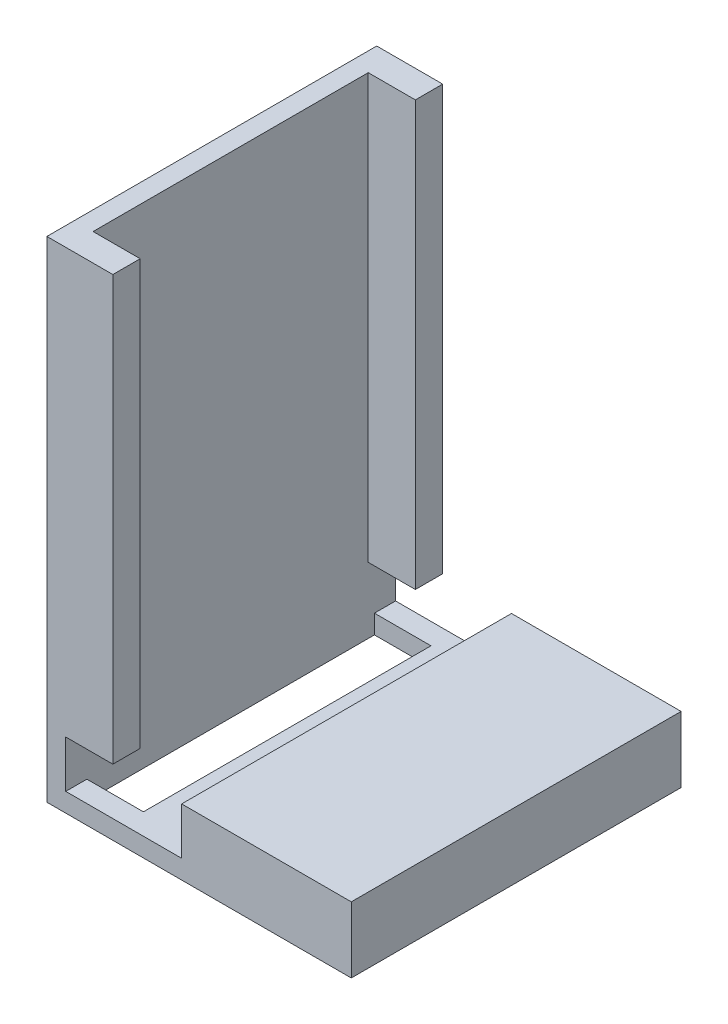
from build123d import *

# Parameters (mm, degrees)
SKETCH1_W           = 18
SKETCH1_H           = 5
SKETCH1_W_2         = 2
SKETCH1_H_2         = 2
SKETCH1_H_3         = 50
BOSS_EXTRUDE1_DEPTH = 35
SKETCH2_W           = 2.9
SKETCH2_H           = 45
BOSS_EXTRUDE2_DEPTH = 5
SKETCH3_W           = 6
SKETCH3_H           = 30.514407746
CUT_EXTRUDE1_DEPTH  = 5


with BuildPart() as part:
    # Sketch1 → Boss-Extrude1 (new body)
    with BuildSketch(Plane.XY):
        with Locations((23.3, 4.5)):
            Rectangle(SKETCH1_W, SKETCH1_H)
        Polygon((2, 2), (2, 0), (32.3, 0), (32.3, 2), (14.3, 2), align=None)
        with Locations((1, 1)):
            Rectangle(SKETCH1_W_2, SKETCH1_H_2)
        with Locations((1, 27)):
            Rectangle(SKETCH1_W_2, SKETCH1_H_3)
    extrude(amount=BOSS_EXTRUDE1_DEPTH)

    # Sketch2 → Boss-Extrude2 (add)
    with BuildSketch(Plane(origin=(2, 0, 0), x_dir=(0, 0, -1), z_dir=(1, 0, 0))):
        with Locations((-33.55, 29.5)):
            Rectangle(SKETCH2_W, SKETCH2_H)
        with Locations((-1.45, 29.5)):
            Rectangle(SKETCH2_W, SKETCH2_H)
    extrude(amount=BOSS_EXTRUDE2_DEPTH)

    # Sketch3 → Cut-Extrude1 (cut)
    with BuildSketch(Plane.XZ):
        with Locations((5, 17.5)):
            Rectangle(SKETCH3_W, SKETCH3_H)
    extrude(amount=-CUT_EXTRUDE1_DEPTH, mode=Mode.SUBTRACT)


solid = part.part
